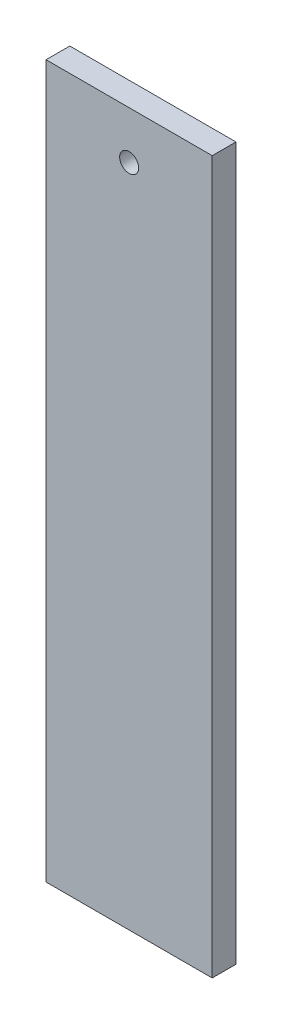
from build123d import *

# Parameters (mm, degrees)
SKETCH1_W           = 35
SKETCH1_H           = 150
BOSS_EXTRUDE1_DEPTH = 5
SKETCH2_R           = 2
CUT_EXTRUDE1_DEPTH  = 6


with BuildPart() as part:
    # Sketch1 → Boss-Extrude1 (new body)
    with BuildSketch(Plane.XY):
        with Locations((17.5, 75)):
            Rectangle(SKETCH1_W, SKETCH1_H)
    extrude(amount=BOSS_EXTRUDE1_DEPTH)

    # Sketch2 → Cut-Extrude1 (cut, through all)
    with BuildSketch(Plane.XY.offset(5)):
        with Locations((17.5, 140)):
            Circle(SKETCH2_R)
    extrude(amount=-CUT_EXTRUDE1_DEPTH, mode=Mode.SUBTRACT)


solid = part.part
